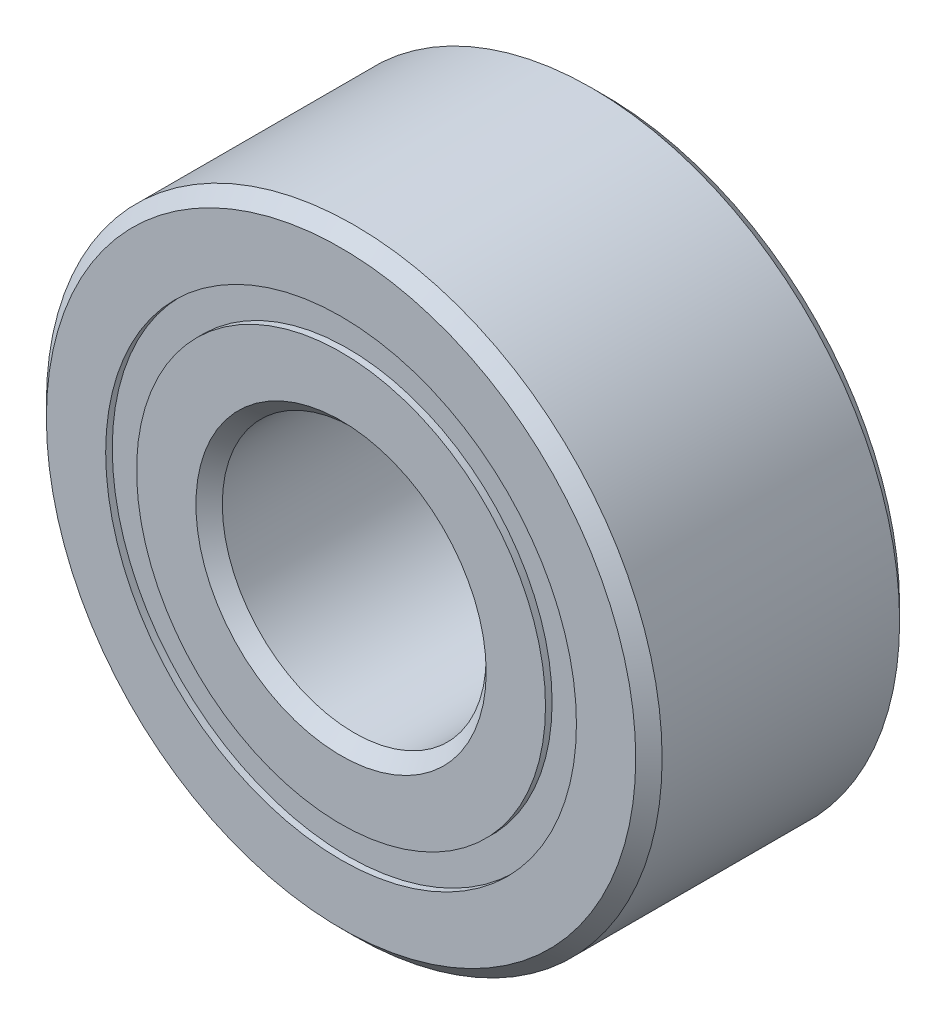
from build123d import *

# Parameters (mm, degrees)
CIRPATTERN1_COUNT = 12
SKETCH5_W         = 0.735537466
SKETCH5_H         = 0.351648352


with BuildPart() as part:
    # Sketch1 → Revolve1 (revolve)
    with BuildSketch(Plane(origin=(0, 0, 0), x_dir=(0, 0, -1), z_dir=(1, 0, 0))):
        with BuildLine():
            Line((1.35, 3.5), (-1.35, 3.5))
            Line((-1.35, 3.5), (-1.5, 3.35))
            Line((-1.5, 3.35), (-1.5, 2.675824176))
            Line((-1.5, 2.675824176), (-0.666666667, 2.675824176))
            ThreePointArc((-0.666666667, 2.675824176), (0, 3.189462534), (0.666666667, 2.675824176))
            Line((0.666666667, 2.675824176), (1.5, 2.675824176))
            Line((1.5, 2.675824176), (1.5, 3.35))
            Line((1.5, 3.35), (1.35, 3.5))
        make_face()
    revolve(axis=Axis((0, 0, 1.5), (0, 0, -1)))


with BuildPart() as body_2:
    # Sketch3 → Revolve3 (revolve)
    with BuildSketch(Plane(origin=(0, 0, 0), x_dir=(0, 0, -1), z_dir=(1, 0, 0))):
        with BuildLine():
            Line((-1.5, 2.324175824), (-0.666666667, 2.324175824))
            ThreePointArc((-0.666666667, 2.324175824), (0, 1.810537466), (0.666666667, 2.324175824))
            Line((0.666666667, 2.324175824), (1.5, 2.324175824))
            Line((1.5, 2.324175824), (1.5, 1.65))
            Line((1.5, 1.65), (1.35, 1.5))
            Line((1.35, 1.5), (-1.35, 1.5))
            Line((-1.35, 1.5), (-1.5, 1.65))
            Line((-1.5, 1.65), (-1.5, 2.324175824))
        make_face()
    revolve(axis=Axis((0, 0, 1.5), (0, 0, -1)))


with BuildPart() as body_3:
    # Sketch4 → Revolve4 (revolve)
    with BuildSketch(Plane(origin=(0, 0, 0), x_dir=(0, 0, -1), z_dir=(1, 0, 0))):
        with BuildLine():
            Line((-0.689462534, 2.5), (0.689462534, 2.5))
            ThreePointArc((0.689462534, 2.5), (0, 3.189462534), (-0.689462534, 2.5))
        make_face()
    revolve(axis=Axis((0, 2.5, 0.689462534), (0, 0, -1)))


with BuildPart() as cirpattern1_1:
    # CirPattern1: pattern copy
    add(body_3.part.rotate(Axis((0, 0, -1.5), (0, 0, 1)), 1 * 360 / CIRPATTERN1_COUNT))


with BuildPart() as cirpattern1_2:
    # CirPattern1: pattern copy
    add(body_3.part.rotate(Axis((0, 0, -1.5), (0, 0, 1)), 2 * 360 / CIRPATTERN1_COUNT))


with BuildPart() as cirpattern1_3:
    # CirPattern1: pattern copy
    add(body_3.part.rotate(Axis((0, 0, -1.5), (0, 0, 1)), 3 * 360 / CIRPATTERN1_COUNT))


with BuildPart() as cirpattern1_4:
    # CirPattern1: pattern copy
    add(body_3.part.rotate(Axis((0, 0, -1.5), (0, 0, 1)), 4 * 360 / CIRPATTERN1_COUNT))


with BuildPart() as cirpattern1_5:
    # CirPattern1: pattern copy
    add(body_3.part.rotate(Axis((0, 0, -1.5), (0, 0, 1)), 5 * 360 / CIRPATTERN1_COUNT))


with BuildPart() as cirpattern1_6:
    # CirPattern1: pattern copy
    add(body_3.part.rotate(Axis((0, 0, -1.5), (0, 0, 1)), 6 * 360 / CIRPATTERN1_COUNT))


with BuildPart() as cirpattern1_7:
    # CirPattern1: pattern copy
    add(body_3.part.rotate(Axis((0, 0, -1.5), (0, 0, 1)), 7 * 360 / CIRPATTERN1_COUNT))


with BuildPart() as cirpattern1_8:
    # CirPattern1: pattern copy
    add(body_3.part.rotate(Axis((0, 0, -1.5), (0, 0, 1)), 8 * 360 / CIRPATTERN1_COUNT))


with BuildPart() as cirpattern1_9:
    # CirPattern1: pattern copy
    add(body_3.part.rotate(Axis((0, 0, -1.5), (0, 0, 1)), 9 * 360 / CIRPATTERN1_COUNT))


with BuildPart() as cirpattern1_10:
    # CirPattern1: pattern copy
    add(body_3.part.rotate(Axis((0, 0, -1.5), (0, 0, 1)), 10 * 360 / CIRPATTERN1_COUNT))


with BuildPart() as cirpattern1_11:
    # CirPattern1: pattern copy
    add(body_3.part.rotate(Axis((0, 0, -1.5), (0, 0, 1)), 11 * 360 / CIRPATTERN1_COUNT))


with BuildPart() as body_15:
    # Sketch5 → Revolve5 (revolve)
    with BuildSketch(Plane(origin=(0, 0, 0), x_dir=(0, 0, -1), z_dir=(1, 0, 0))):
        with Locations((-1.057231267, 2.5)):
            Rectangle(SKETCH5_W, SKETCH5_H)
        with Locations((1.057231267, 2.5)):
            Rectangle(SKETCH5_W, SKETCH5_H)
    revolve(axis=Axis((0, 0, 1.5), (0, 0, -1)))


solid = Compound([part.part, body_2.part, body_3.part, cirpattern1_1.part, cirpattern1_2.part, cirpattern1_3.part, cirpattern1_4.part, cirpattern1_5.part, cirpattern1_6.part, cirpattern1_7.part, cirpattern1_8.part, cirpattern1_9.part, cirpattern1_10.part, cirpattern1_11.part, body_15.part])
